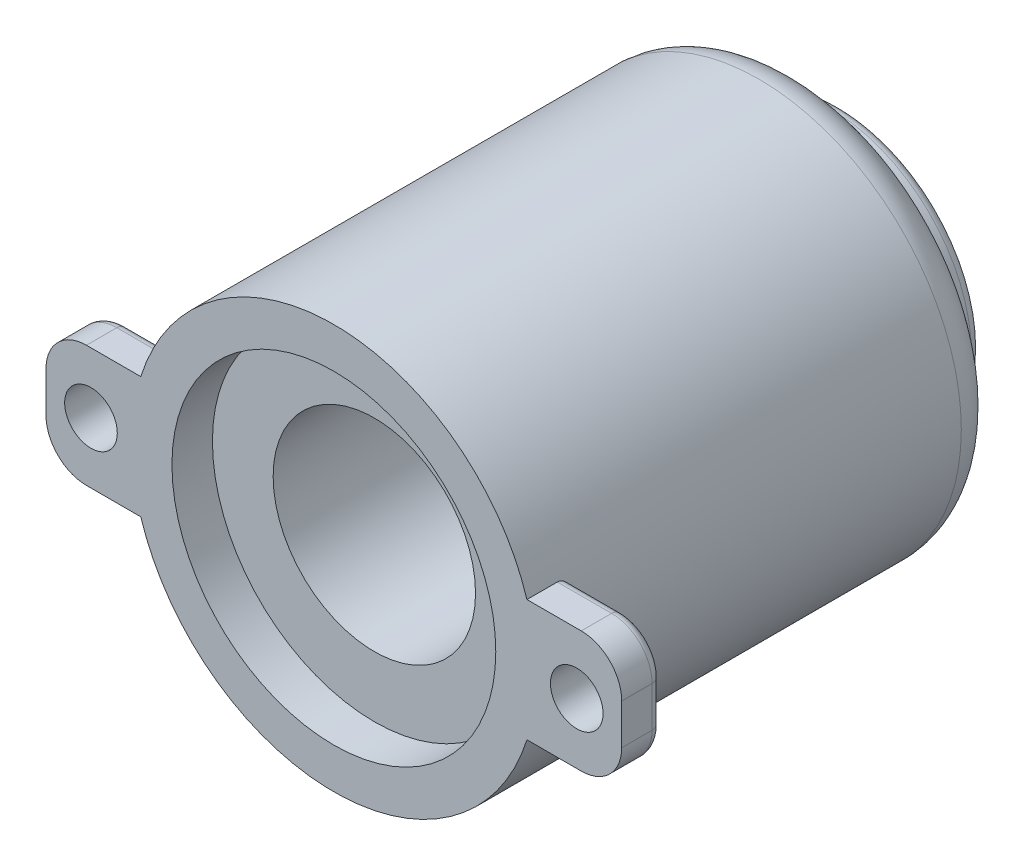
from build123d import *

# Parameters (mm, degrees)
SKETCH1_R               = 10
BOSS_EXTRUDE1_DEPTH     = 25
CUT_EXTRUDE2_DEPTH      = 29.722813233
CUT_EXTRUDE2_DEPTH_BACK = 25
SKETCH1_3_R             = 5
SKETCH1_7_R             = 10
SKETCH1_7_R_2           = 7
CUT_EXTRUDE3_DEPTH      = 2
SKETCH5_R               = 8
CUT_EXTRUDE4_DEPTH      = 2
BOSS_EXTRUDE2_START     = -2
SKETCH6_R               = 1.3
BOSS_EXTRUDE2_DEPTH     = 2
FILLET1_R               = 2
FILLET2_R               = 0.5


with BuildPart() as part:
    # Sketch1 → Boss-Extrude1 (new body)
    with BuildSketch(Plane.XY):
        Circle(SKETCH1_R)
    extrude(amount=BOSS_EXTRUDE1_DEPTH)

    # Sketch1_3 → Cut-Extrude2 (cut, two sides: drawn at the far end of the back side and taken through both)
    with BuildSketch(Plane.XY.offset(-CUT_EXTRUDE2_DEPTH_BACK)):
        Circle(SKETCH1_3_R)
    extrude(amount=CUT_EXTRUDE2_DEPTH + CUT_EXTRUDE2_DEPTH_BACK, mode=Mode.SUBTRACT)

    # Sketch1_7 → Cut-Extrude3 (cut)
    with BuildSketch(Plane.XY):
        Circle(SKETCH1_7_R)
        Circle(SKETCH1_7_R_2, mode=Mode.SUBTRACT)
    extrude(amount=CUT_EXTRUDE3_DEPTH, mode=Mode.SUBTRACT)

    # Sketch5 → Cut-Extrude4 (cut)
    with BuildSketch(Plane.XY.offset(25)):
        Circle(SKETCH5_R)
    extrude(amount=-CUT_EXTRUDE4_DEPTH, mode=Mode.SUBTRACT)

    # Sketch6 → Boss-Extrude2 (add)
    # profile 1 of 2: a face of its own
    with BuildSketch(Plane.XY.offset(25).offset(BOSS_EXTRUDE2_START)):
        with BuildLine():
            Line((-14.222467655, 1), (-14.222467655, -1))
            ThreePointArc((-14.222467655, -1), (-13.636681217, -2.414213562), (-12.222467655, -3))
            Line((-12.222467655, -3), (-9.539392014, -3))
            ThreePointArc((-9.539392014, -3), (-10, 0), (-9.539392014, 3))
            Line((-9.539392014, 3), (-12.222467655, 3))
            ThreePointArc((-12.222467655, 3), (-13.636681217, 2.414213562), (-14.222467655, 1))
        make_face()
        with Locations((-12, 0)):
            Circle(SKETCH6_R, mode=Mode.SUBTRACT)
    # profile 2 of 2: a face of its own
    with BuildSketch(Plane.XY.offset(25).offset(BOSS_EXTRUDE2_START)):
        with BuildLine():
            ThreePointArc((9.539392014, 3), (10, 0), (9.539392014, -3))
            Line((9.539392014, -3), (12.222467655, -3))
            ThreePointArc((12.222467655, -3), (13.636681217, -2.414213562), (14.222467655, -1))
            Line((14.222467655, -1), (14.222467655, 1))
            ThreePointArc((14.222467655, 1), (13.636681217, 2.414213562), (12.222467655, 3))
            Line((12.222467655, 3), (9.539392014, 3))
        make_face()
        with Locations((12, 0)):
            Circle(SKETCH6_R, mode=Mode.SUBTRACT)
    extrude(amount=BOSS_EXTRUDE2_DEPTH)

    # Fillet1
    fillet1_edges = [part.edges().sort_by_distance(p)[0] for p in [
        (-10, 0, 2),
    ]]
    fillet(fillet1_edges, radius=FILLET1_R)

    # Fillet2
    fillet2_edges = [part.edges().sort_by_distance(p)[0] for p in [
        (10.880929834, -3, 23),
        (13.636681217, -2.414213562, 23),
        (10.880929834, 3, 23),
        (13.636681217, 2.414213562, 23),
        (-10.880929834, -3, 23),
        (-13.636681217, -2.414213562, 23),
        (-14.222467655, 0, 23),
        (-13.636681217, 2.414213562, 23),
        (-7, 0, 0),
        (-7, 0, 2),
        (14.222467655, 0, 23),
        (-10.880929834, 3, 23),
    ]]
    fillet(fillet2_edges, radius=FILLET2_R)


solid = part.part
